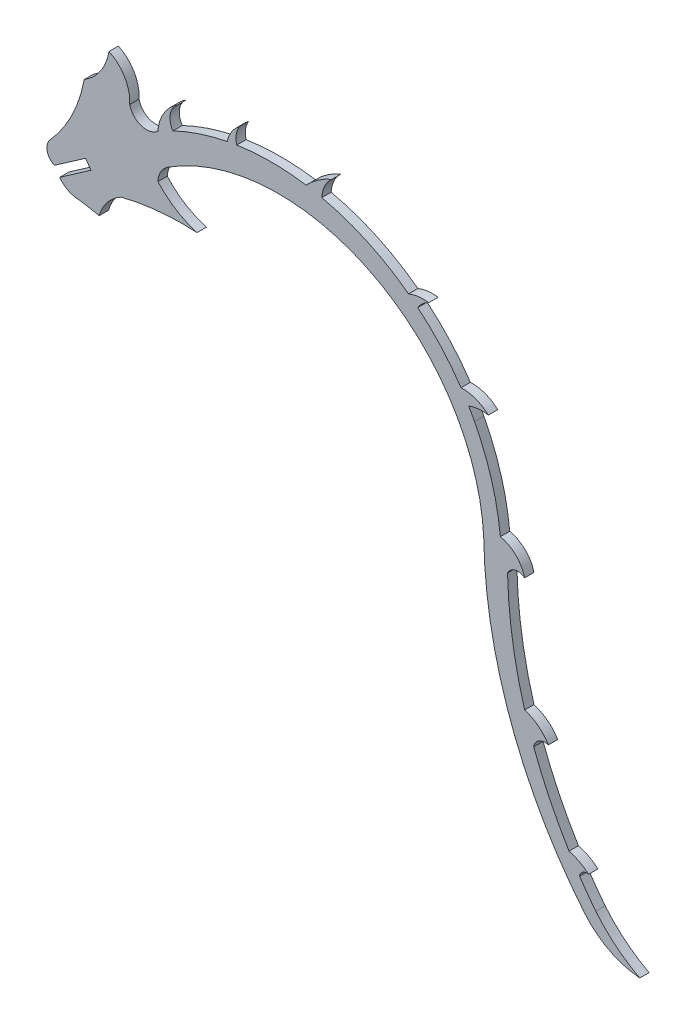
from build123d import *

# Parameters (mm, degrees)
BOSS_EXTRUDE1_DEPTH = 1.524


with BuildPart() as part:
    # Sketch1 → Boss-Extrude1 (new body)
    with BuildSketch(Plane.XY):
        with BuildLine():
            Line((-39.117691612, 31.705702494), (-34.035061267, 35.245462587))
            Line((-34.035061267, 35.245462587), (-34.907334502, 36.4982372))
            Line((-34.907334502, 36.4982372), (-39.989964847, 32.957484201))
            ThreePointArc((-39.989964847, 32.957484201), (-41.156381442, 34.371130843), (-40.72943499, 36.153444291))
            ThreePointArc((-40.72943499, 36.153444291), (-37.157257908, 41.392315435), (-35.149645056, 47.406940162))
            ThreePointArc((-35.149645056, 47.406940162), (-35.150000593, 47.436618983), (-35.150119107, 47.466299697))
            ThreePointArc((-35.150119107, 47.466299697), (-32.474220558, 50.029100651), (-31.092386734, 53.46696584))
            ThreePointArc((-31.092386734, 53.46696584), (-28.528895289, 51.083388449), (-27.722652605, 47.677085129))
            ThreePointArc((-27.722652605, 47.677085129), (-25.864549179, 45.627042683), (-23.153757297, 46.180964831))
            ThreePointArc((-23.153757297, 46.180964831), (-22.178534836, 49.206145698), (-19.954812919, 51.477233316))
            ThreePointArc((-19.954812919, 51.477233316), (-21.130091376, 49.619411518), (-20.702707555, 47.462996819))
            ThreePointArc((-20.702707555, 47.462996819), (-16.368548246, 49.204688548), (-11.850579294, 50.390598976))
            ThreePointArc((-11.850579294, 50.390598976), (-11.153919, 52.10102423), (-9.892322836, 53.449825638))
            ThreePointArc((-9.892322836, 53.449825638), (-10.390962499, 52.098435339), (-10.305463017, 50.66052467))
            ThreePointArc((-10.305463017, 50.66052467), (-4.659496824, 51.089737509), (0.986334207, 50.658750415))
            ThreePointArc((0.986334207, 50.658750415), (2.931593893, 52.336657489), (5.181027531, 53.577405529))
            ThreePointArc((5.181027531, 53.577405529), (4.013781328, 52.043650888), (3.542618472, 50.174728054))
            ThreePointArc((3.542618472, 50.174728054), (10.941086412, 47.665032068), (17.653861509, 43.668214296))
            ThreePointArc((17.653861509, 43.668214296), (19.271772807, 44.086118721), (20.942706276, 44.069919276))
            ThreePointArc((20.942706276, 44.069919276), (19.933918295, 43.40682582), (19.151343007, 42.48762941))
            ThreePointArc((19.151343007, 42.48762941), (22.950326986, 38.849120016), (26.199236503, 34.712017549))
            ThreePointArc((26.199236503, 34.712017549), (28.587130465, 34.336897034), (30.651629038, 33.079678433))
            ThreePointArc((30.651629038, 33.079678433), (29.023098561, 33.126789379), (27.436671978, 32.755869369))
            ThreePointArc((27.436671978, 32.755869369), (27.926256891, 31.900308765), (28.393045297, 31.032100312))
            ThreePointArc((28.393045297, 31.032100312), (31.169330508, 24.1759064), (32.596114117, 16.917845842))
            ThreePointArc((32.596114117, 16.917845842), (35.116195442, 15.563753706), (36.545589929, 13.085607866))
            ThreePointArc((36.545589929, 13.085607866), (34.988216261, 13.405663895), (33.766569049, 12.388104711))
            ThreePointArc((33.766569049, 12.388104711), (34.557842987, 3.332770711), (36.545589929, -5.537068656))
            ThreePointArc((36.545589929, -5.537068656), (38.757623722, -6.672814151), (40.411337246, -8.52975866))
            ThreePointArc((40.411337246, -8.52975866), (38.887733864, -8.706049408), (38.022049175, -9.972159875))
            ThreePointArc((38.022049175, -9.972159875), (40.611583977, -16.03077135), (43.773329776, -21.811413788))
            ThreePointArc((43.773329776, -21.811413788), (45.465168408, -22.463416845), (46.96111524, -23.487901602))
            ThreePointArc((46.96111524, -23.487901602), (46.009909008, -23.664428409), (45.493072894, -24.482252008))
            ThreePointArc((45.493072894, -24.482252008), (46.778816766, -26.31501847), (48.123987434, -28.104623476))
            ThreePointArc((48.123987434, -28.104623476), (51.40918984, -31.384637985), (55.283874059, -33.941564308))
            ThreePointArc((55.283874059, -33.941564308), (50.301959018, -32.513729239), (46.276855411, -29.249264289))
            ThreePointArc((46.276855411, -29.249264289), (34.30827338, -8.358491308), (29.894604694, 15.309860564))
            ThreePointArc((29.894604694, 15.309860564), (11.897133565, 43.455618791), (-21.477635315, 41.96649978))
            ThreePointArc((-21.477635315, 41.96649978), (-22.656445953, 40.735662089), (-23.136633245, 39.10043241))
            ThreePointArc((-23.136633245, 39.10043241), (-20.241057696, 36.637371423), (-16.767124999, 35.093733251))
            ThreePointArc((-16.767124999, 35.093733251), (-22.9849523, 34.969630573), (-29.11414449, 33.916169174))
            ThreePointArc((-29.11414449, 33.916169174), (-31.355074443, 32.068657032), (-32.706500842, 29.497914951))
            ThreePointArc((-32.706500842, 29.497914951), (-34.36207957, 29.840980807), (-36.03028603, 30.116157682))
            ThreePointArc((-36.03028603, 30.116157682), (-37.766569844, 30.536876005), (-39.117691612, 31.705702494))
        make_face()
    extrude(amount=BOSS_EXTRUDE1_DEPTH)


solid = part.part
